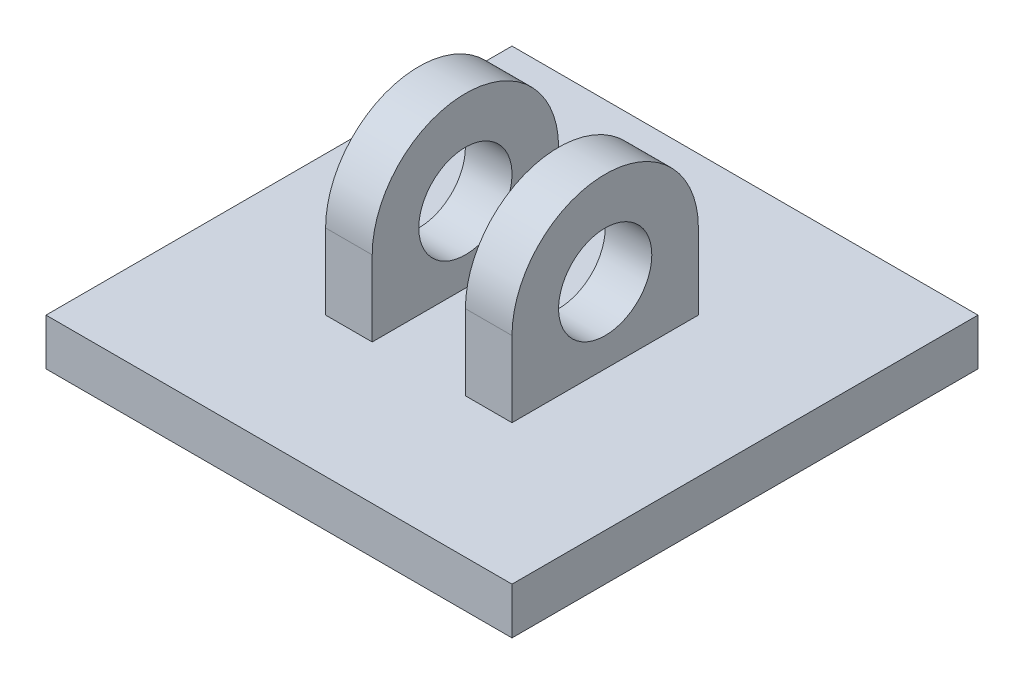
from build123d import *

# Parameters (mm, degrees)
SKETCH1_W           = 50
SKETCH1_H           = 5
BOSS_EXTRUDE1_DEPTH = 50
BOSS_EXTRUDE2_DEPTH = 5
SKETCH3_R           = 5
CUT_EXTRUDE1_DEPTH  = 36


with BuildPart() as part:
    # Sketch1 → Boss-Extrude1 (new body)
    with BuildSketch(Plane.XY):
        with Locations((0, 2.5)):
            Rectangle(SKETCH1_W, SKETCH1_H)
    extrude(amount=-BOSS_EXTRUDE1_DEPTH)

    # Sketch2 → Boss-Extrude2 (add)
    with BuildSketch(Plane(origin=(5, 0, 0), x_dir=(0, 0, -1), z_dir=(1, 0, 0))):
        with BuildLine():
            Line((15, 5), (35, 5))
            Line((35, 5), (35, 13.097700543))
            ThreePointArc((35, 13.097700543), (25, 23.097700543), (15, 13.097700543))
            Line((15, 13.097700543), (15, 5))
        make_face()
    boss_extrude2 = extrude(amount=BOSS_EXTRUDE2_DEPTH)

    # Sketch3 → Cut-Extrude1 (cut, through all)
    with BuildSketch(Plane(origin=(10, 0, 0), x_dir=(0, 0, -1), z_dir=(1, 0, 0))):
        with Locations((25, 13.097700543)):
            Circle(SKETCH3_R)
    cut_extrude1 = extrude(amount=-CUT_EXTRUDE1_DEPTH, mode=Mode.SUBTRACT)

    # Mirror1: Boss-Extrude2, Cut-Extrude1 across plane
    add(boss_extrude2.mirror(Plane(origin=(0, 0, 0), x_dir=(0, 0, 1), z_dir=(1, 0, 0))))
    add(cut_extrude1.mirror(Plane(origin=(0, 0, 0), x_dir=(0, 0, 1), z_dir=(1, 0, 0))), mode=Mode.SUBTRACT)


solid = part.part
